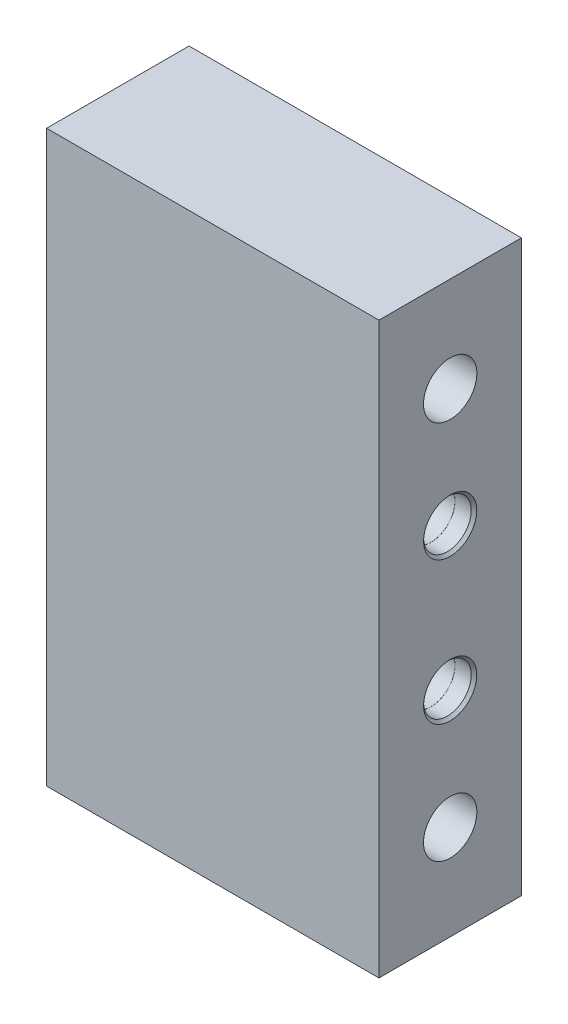
from build123d import *

# Parameters (mm, degrees)
SKETCH1_W                      = 44.45
SKETCH1_H                      = 76.2
EXTRUDE1_DEPTH                 = 19.05
F_1_4_CLEARANCE_HOLE1_D        = 7.14248
CBORE_FOR_1_4_DOWEL_AT_2_COUNT = 2
CBORE_FOR_1_4_DOWEL_AT_2_PITCH = 19.05
F_3_16_0_1875_DIAMETER_HOLE1_D = 4.7625


with BuildPart() as part:
    # Sketch1 → Extrude1 (new body)
    with BuildSketch(Plane.XY):
        Rectangle(SKETCH1_W, SKETCH1_H)
    extrude(amount=EXTRUDE1_DEPTH)

    # 1/4 Clearance Hole1 (through all)
    with Locations(Plane(origin=(22.225, 0, 0), x_dir=(0, 0, -1), z_dir=(1, 0, 0))):
        with Locations((-9.525, 25.4), (-9.525, -25.4)):
            Hole(F_1_4_CLEARANCE_HOLE1_D / 2)

    # Sketch4 → CBORE for 1/4 DOWEL (revolve, cut)
    with BuildSketch(Plane(origin=(22.225, -9.525, 9.525), x_dir=(0, 0, -1), z_dir=(0, 1, 0))):
        Polygon((0, 0), (0, 11.559732465), (3.175, 9.652), (3.175, 2.54), (3.1877, 2.54), (3.1877, 0.3683), (3.556, 0), align=None)
    cbore_for_1_4_dowel = revolve(axis=Axis((28.575, -9.525, 9.525), (-1, 0, 0)), mode=Mode.SUBTRACT)

    # CBORE for 1/4 DOWEL at 2: CBORE for 1/4 DOWEL ×2
    with Locations(*[(0, i * CBORE_FOR_1_4_DOWEL_AT_2_PITCH, 0) for i in range(1, CBORE_FOR_1_4_DOWEL_AT_2_COUNT)]):
        add(cbore_for_1_4_dowel, mode=Mode.SUBTRACT)

    # 3/16 (0.1875) Diameter Hole1 (through all)
    with Locations(Plane(origin=(22.225, 0, 0), x_dir=(0, 0, -1), z_dir=(1, 0, 0))):
        with Locations((-9.525, 9.525), (-9.525, -9.525)):
            Hole(F_3_16_0_1875_DIAMETER_HOLE1_D / 2)

    # Mirror1: CBORE for 1/4 DOWEL across plane
    add(cbore_for_1_4_dowel.mirror(Plane(origin=(0, 0, 0), x_dir=(0, 0, 1), z_dir=(1, 0, 0))), mode=Mode.SUBTRACT)

    # Mirror1 copy 1 sketch → Mirror1 copy 1 (revolve, cut)
    with BuildSketch(Plane(origin=(-22.225, 9.525, 9.525), x_dir=(0, 0, -1), z_dir=(0, 1, 0))):
        Polygon((0, 0), (0, -11.559732465), (3.175, -9.652), (3.175, -2.54), (3.1877, -2.54), (3.1877, -0.3683), (3.556, 0), align=None)
    revolve(axis=Axis((-28.575, 9.525, 9.525), (-1, 0, 0)), mode=Mode.SUBTRACT)


solid = part.part
